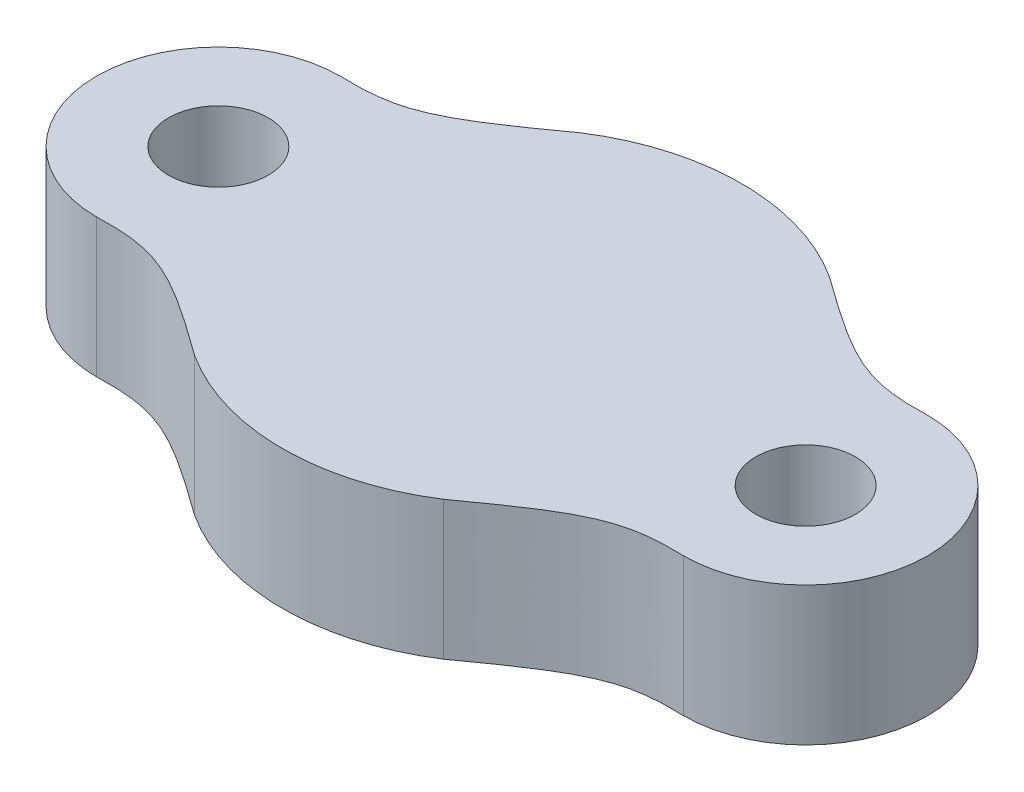
from build123d import *

# Parameters (mm, degrees)
CROQUIS1_R              = 1.143
SALIENTE_EXTRUIR8_DEPTH = 3.175


with BuildPart() as part:
    # Croquis1 → Saliente-Extruir8 (new body)
    with BuildSketch(Plane(origin=(0, 0, 0), x_dir=(1, 0, 0), z_dir=(0, 1, 0))):
        with BuildLine():
            ThreePointArc((-16.851199999, 4.270284963), (-19.645199999, 1.476284963), (-16.851199999, -1.317715037))
            add(Edge.make_bspline(
                [(-16.851199999, -1.317715037), (-15.450840408, -1.268925893), (-14.877323423, -1.566939978), (-12.975113768, -2.944503837)],
                knots=[0, 0, 0, 0, 1, 1, 1, 1], degree=3))
            ThreePointArc((-12.975113768, -2.944503837), (-10.120199999, -3.786215037), (-7.265286229, -2.944503837))
            add(Edge.make_bspline(
                [(-7.265286229, -2.944503837), (-5.363076574, -1.566939978), (-4.789559589, -1.268925893), (-3.389199999, -1.317715037)],
                knots=[0.921934519, 0.921934519, 0.921934519, 0.921934519, 1.921934519, 1.921934519, 1.921934519, 1.921934519], degree=3))
            ThreePointArc((-3.389199999, -1.317715037), (-0.595199999, 1.476284963), (-3.389199999, 4.270284963))
            add(Edge.make_bspline(
                [(-3.389199999, 4.270284963), (-4.789559589, 4.221495819), (-5.363076574, 4.519509904), (-7.265286229, 5.897073763)],
                knots=[0, 0, 0, 0, 1, 1, 1, 1], degree=3))
            ThreePointArc((-7.265286229, 5.897073763), (-10.120199999, 6.738784963), (-12.975113768, 5.897073763))
            add(Edge.make_bspline(
                [(-12.975113768, 5.897073763), (-14.877323423, 4.519509904), (-15.450840408, 4.221495819), (-16.851199999, 4.270284963)],
                knots=[0.921934519, 0.921934519, 0.921934519, 0.921934519, 1.921934519, 1.921934519, 1.921934519, 1.921934519], degree=3))
        make_face()
        with Locations((-16.851199999, 1.476284963)):
            Circle(CROQUIS1_R, mode=Mode.SUBTRACT)
        with Locations((-3.389199999, 1.476284963)):
            Circle(CROQUIS1_R, mode=Mode.SUBTRACT)
    extrude(amount=SALIENTE_EXTRUIR8_DEPTH)


solid = part.part
